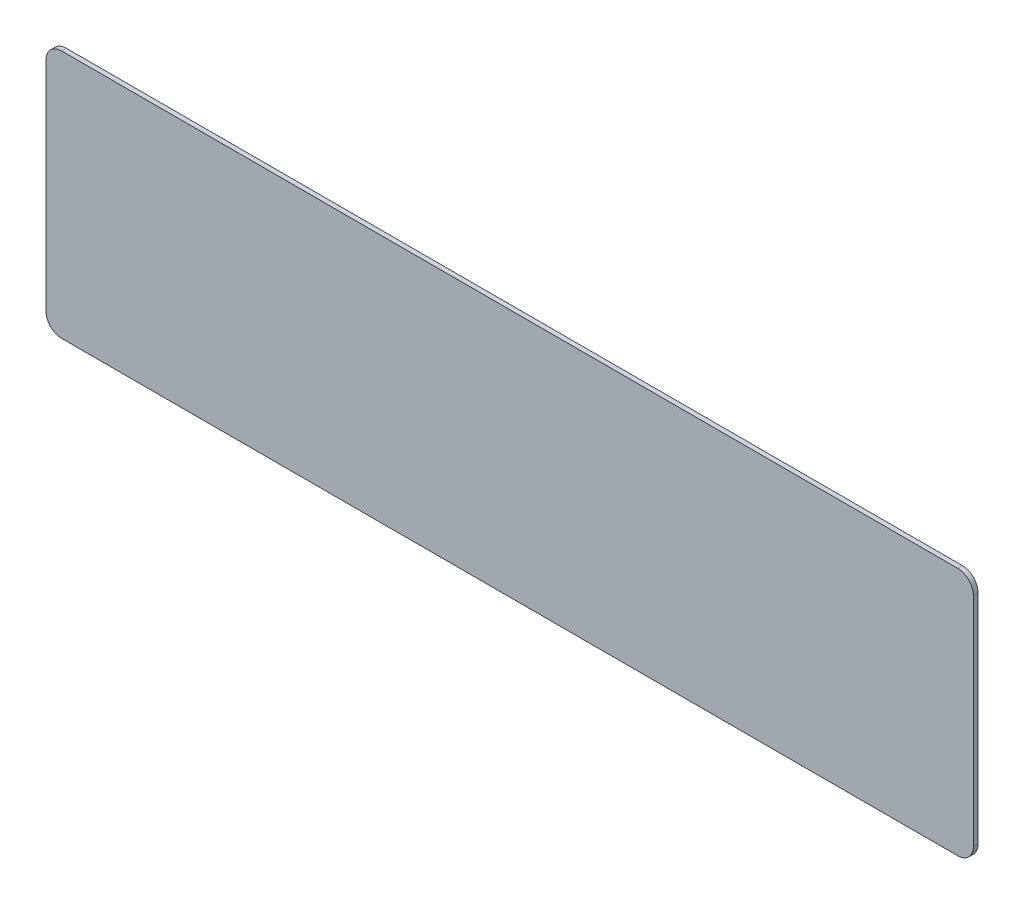
from build123d import *

# Parameters (mm, degrees)
RESSALTO_EXTRUS_O1_DEPTH = 1.5


with BuildPart() as part:
    # Esboço1 → Ressalto-extrusão1 (new body)
    with BuildSketch(Plane.XY):
        with BuildLine():
            Line((5, 0), (293, 0))
            ThreePointArc((293, 0), (296.535533906, 1.464466094), (298, 5))
            Line((298, 5), (298, 75))
            ThreePointArc((298, 75), (296.535533906, 78.535533906), (293, 80))
            Line((293, 80), (5, 80))
            ThreePointArc((5, 80), (1.464466094, 78.535533906), (0, 75))
            Line((0, 75), (0, 5))
            ThreePointArc((0, 5), (1.464466094, 1.464466094), (5, 0))
        make_face()
    extrude(amount=RESSALTO_EXTRUS_O1_DEPTH)


solid = part.part
